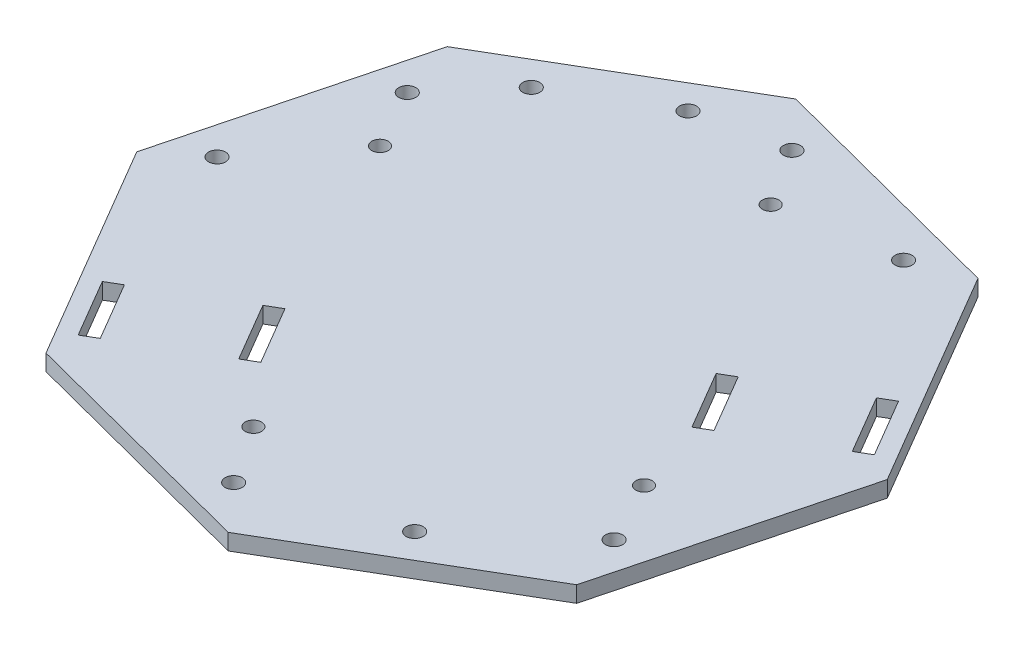
from build123d import *

# Parameters (mm, degrees)
BOSS_EXTRUDE1_DEPTH = 3
SKETCH2_R           = 1.5875
SKETCH2_R_2         = 1.524
CUT_EXTRUDE1_DEPTH  = 3


with BuildPart() as part:
    # Sketch1 → Boss-Extrude1 (new body)
    with BuildSketch(Plane(origin=(-113.226454214, -170.109741769, -309.439751514), x_dir=(0.890793361, 0, -0.454408614), z_dir=(0, -1, 0))):
        Polygon((16.200077076, -64.648683729), (51.592412285, -33.201987218), (54.382400165, 14.060345359), (22.935703655, 49.452680569), (-24.326628923, 52.242668449), (-59.718964132, 20.795971938), (-62.508952012, -26.466360639), (-31.062255502, -61.858695849), align=None)
    extrude(amount=BOSS_EXTRUDE1_DEPTH)

    # Sketch2 → Cut-Extrude1 (cut)
    with BuildSketch(Plane.XZ.offset(173.109741769)):
        with Locations((-172.64368154, -311.255818085)):
            Circle(SKETCH2_R)
        with Locations((-165.337130549, -339.316642084)):
            Circle(SKETCH2_R)
        with Locations((-154.635807236, -351.670528307)):
            Circle(SKETCH2_R)
        with Locations((-159.276542973, -328.182647353)):
            Circle(SKETCH2_R_2)
        with Locations((-125.832608107, -271.190808365)):
            Circle(SKETCH2_R_2)
        with Locations((-118.673164362, -260.366927273)):
            Circle(SKETCH2_R)
        with Locations((-80.052844095, -298.055276559)):
            Circle(SKETCH2_R_2)
        with Locations((-74.095129755, -286.526196957)):
            Circle(SKETCH2_R)
        with Locations((-136.265254, -362.450731171)):
            Circle(SKETCH2_R)
        with Locations((-120.261137836, -365.768123404)):
            Circle(SKETCH2_R)
        with Locations((-113.496778962, -355.047115547)):
            Circle(SKETCH2_R_2)
        with Locations((-92.200313837, -358.461572413)):
            Circle(SKETCH2_R)
        with Locations((-93.954162759, -269.305623721)):
            Circle(SKETCH2_R)
        Polygon((-163.258580453, -280.538613217), (-160.671178566, -282.056951662), (-154.290364989, -271.183401601), (-156.877766876, -269.665063156), align=None)
        Polygon((-144.485366677, -291.620563992), (-141.897964791, -293.138902436), (-135.511480905, -282.255689599), (-138.098882792, -280.737351154), align=None)
        Polygon((-63.58013806, -324.413951361), (-66.167539946, -322.895612916), (-72.548353524, -333.769162977), (-69.960951637, -335.287501422), align=None)
        Polygon((-82.404827782, -313.419720793), (-84.992229669, -311.901382348), (-91.378713554, -322.784595186), (-88.791311667, -324.302933631), align=None)
    extrude(amount=-CUT_EXTRUDE1_DEPTH, mode=Mode.SUBTRACT)


solid = part.part
